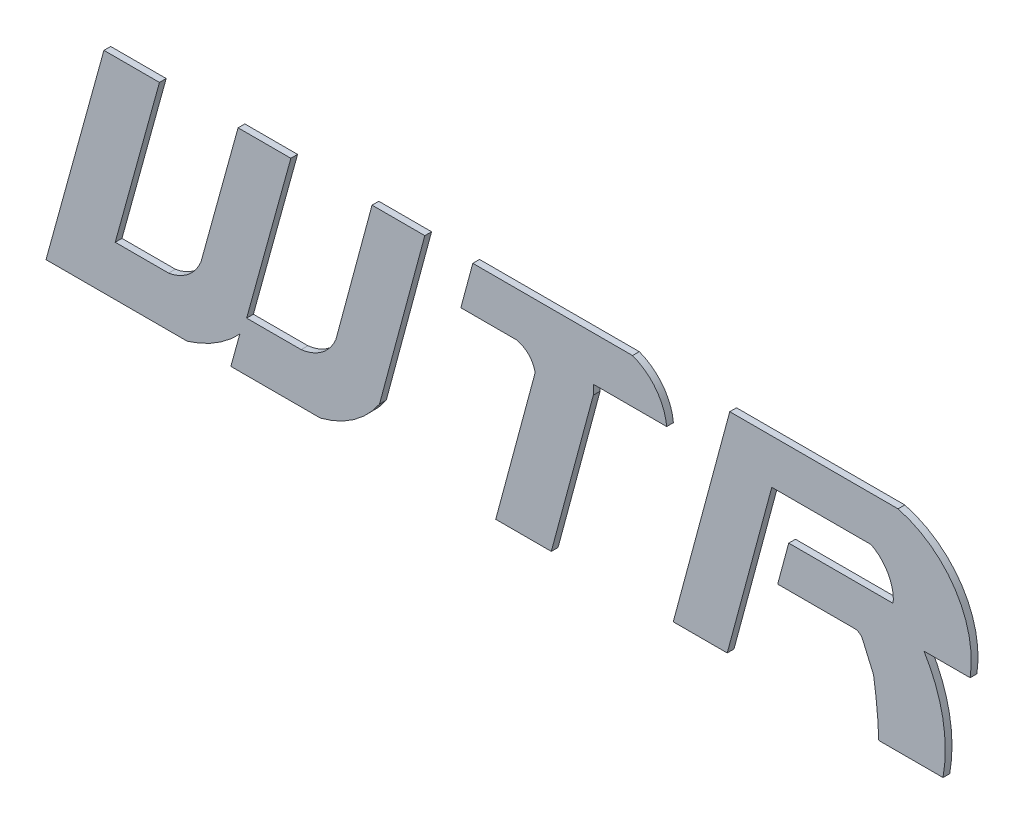
from build123d import *

# Parameters (mm, degrees)
EXTRUDE_1_DEPTH   = 10
EXTRUDE_1_2_DEPTH = 10
EXTRUDE_1_3_DEPTH = 10


with BuildPart() as part:
    # 草图2 → 凸台-拉伸1 (new body)
    with BuildSketch(Plane.XY):
        with BuildLine():
            Line((389.304357809, 1163.23580449), (303.474237897, 851.660711656))
            Line((303.474237897, 851.660711656), (512.758639876, 851.660711656))
            ThreePointArc((512.758639876, 851.660711656), (554.806216723, 870.581471484), (590.632848169, 899.606397847))
            Line((590.632848169, 899.606397847), (577.425168577, 851.660711656))
            Line((577.425168577, 851.660711656), (710.285491182, 851.660711656))
            ThreePointArc((710.285491182, 851.660711656), (759.686692865, 874.506623445), (797.717714769, 913.443184491))
            Line((797.717714769, 913.443184491), (864.867417156, 1163.23580449))
            Line((864.867417156, 1163.23580449), (786.65747616, 1163.23580449))
            Line((786.65747616, 1163.23580449), (733.059055058, 963.853088573))
            ThreePointArc((733.059055058, 963.853088573), (712.565608986, 937.621046524), (681.648324613, 925.283182489))
            Line((681.648324613, 925.283182489), (600.785277159, 925.283182489))
            Line((600.785277159, 925.283182489), (666.334490012, 1163.23580449))
            Line((666.334490012, 1163.23580449), (588.124549016, 1163.23580449))
            Line((588.124549016, 1163.23580449), (533.200253688, 963.853088573))
            ThreePointArc((533.200253688, 963.853088573), (514.288966473, 938.225748677), (485.187638071, 925.283182489))
            Line((485.187638071, 925.283182489), (406.057999667, 925.283182489))
            Line((406.057999667, 925.283182489), (471.60721252, 1163.23580449))
            Line((471.60721252, 1163.23580449), (389.304357809, 1163.23580449))
        make_face()
    extrude(amount=EXTRUDE_1_DEPTH)


with BuildPart() as body_2:
    # 草图2 → Extrude 1 2 (new body)
    with BuildSketch(Plane.XY):
        with BuildLine():
            Line((918.257169442, 1097.357315535), (935.966743596, 1163.23580449))
            Line((935.966743596, 1163.23580449), (1172.701909333, 1163.23580449))
            ThreePointArc((1172.701909333, 1163.23580449), (1207.399065731, 1137.517487269), (1223.288845751, 1097.357315535))
            Line((1223.288845751, 1097.357315535), (1114.564683898, 1097.357315535))
            Line((1114.564683898, 1097.357315535), (1114.564683898, 1083.298446825))
            Line((1114.564683898, 1083.298446825), (1052.295410378, 851.660711656))
            Line((1052.295410378, 851.660711656), (969.936486198, 851.660711656))
            Line((969.936486198, 851.660711656), (1028.350310788, 1068.956422133))
            ThreePointArc((1028.350310788, 1068.956422133), (1018.89847646, 1087.507686659), (1000.555319733, 1097.357315535))
            Line((1000.555319733, 1097.357315535), (918.257169442, 1097.357315535))
        make_face()
    extrude(amount=EXTRUDE_1_2_DEPTH)


with BuildPart() as body_3:
    # 草图2 → Extrude 1 3 (new body)
    with BuildSketch(Plane.XY):
        with BuildLine():
            Line((1316.764838946, 1163.23580449), (1233.006660842, 851.660711656))
            Line((1233.006660842, 851.660711656), (1313, 851.660711656))
            Line((1313, 851.660711656), (1379.04860395, 1097.357315535))
            Line((1379.04860395, 1097.357315535), (1526.283569879, 1097.357315535))
            ThreePointArc((1526.283569879, 1097.357315535), (1551.510533942, 1072.705066269), (1558.970888517, 1038.23078282))
            Line((1558.970888517, 1038.23078282), (1404.129264317, 1038.23078282))
            Line((1404.129264317, 1038.23078282), (1387.774136575, 977.390748332))
            Line((1387.774136575, 977.390748332), (1499.959107971, 977.390748332))
            ThreePointArc((1499.959107971, 977.390748332), (1508.174821309, 975.567354772), (1513.74369718, 969.257811899))
            Line((1513.74369718, 969.257811899), (1529.848203758, 932.050848425))
            ThreePointArc((1529.848203758, 932.050848425), (1534.962350336, 891.975276923), (1537.597071169, 851.660711656))
            Line((1537.597071169, 851.660711656), (1632.797442216, 851.660711656))
            ThreePointArc((1632.797442216, 851.660711656), (1632.395943132, 928.370264407), (1604.55062793, 999.848618515))
            Line((1604.55062793, 999.848618515), (1673, 999.848618515))
            ThreePointArc((1673, 999.848618515), (1650.919123277, 1102.030824802), (1566.168200806, 1163.23580449))
            Line((1566.168200806, 1163.23580449), (1316.764838946, 1163.23580449))
        make_face()
    extrude(amount=EXTRUDE_1_3_DEPTH)


solid = Compound([part.part, body_2.part, body_3.part])
